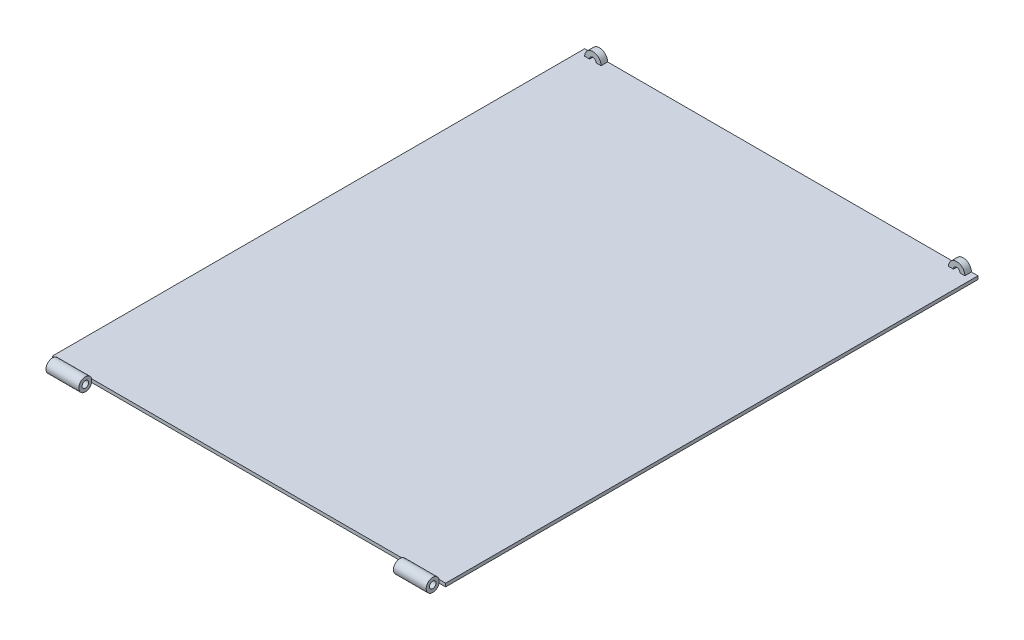
from build123d import *

# Parameters (mm, degrees)
SKETCH1_W                       = 60
SKETCH1_H                       = 82.18
BOSS_EXTRUDE1_DEPTH             = 0.5
BOSS_EXTRUDE2_REACH             = 32
SKETCH3_R                       = 1
SKETCH3_R_2                     = 0.5
BOSS_EXTRUDE2_DIRECTION_2_REACH = 32
SKETCH4_R                       = 0.5
CUT_EXTRUDE1_DEPTH              = 61
SKETCH5_W                       = 48
SKETCH5_H                       = 1.968245837
SKETCH5_W_2                     = 1
CUT_EXTRUDE2_DEPTH              = 1.75
CUT_EXTRUDE2_DEPTH_BACK         = 2.25
BOSS_EXTRUDE3_DEPTH             = 1


with BuildPart() as part:
    # Sketch1 → Boss-Extrude1 (new body)
    with BuildSketch(Plane(origin=(0, 0, 0), x_dir=(1, 0, 0), z_dir=(0, 1, 0))):
        Rectangle(SKETCH1_W, SKETCH1_H)
    extrude(amount=BOSS_EXTRUDE1_DEPTH)

    # Boss-Extrude2: up to this face of the body (flat: up to its plane)
    boss_extrude2_end = Plane(part.part.faces().sort_by_distance((30, 0.25, 0))[0])
    # Sketch3 → Boss-Extrude2 (add, up to the picked face)
    with BuildSketch(Plane(origin=(0, 0, 0), x_dir=(0, 0, -1), z_dir=(1, 0, 0)), mode=Mode.PRIVATE) as boss_extrude2_sk1:
        with Locations((-41.09, 0.25)):
            Circle(SKETCH3_R)
        with Locations((-41.09, 0.25)):
            Circle(SKETCH3_R_2, mode=Mode.SUBTRACT)
    boss_extrude2_tool1 = split(extrude(boss_extrude2_sk1.sketch, amount=BOSS_EXTRUDE2_REACH, mode=Mode.PRIVATE), bisect_by=boss_extrude2_end, keep=Keep.BOTH, mode=Mode.PRIVATE)
    add(boss_extrude2_tool1.solids().sort_by_distance((0, 0.25, 42.061716))[0])

    # Boss-Extrude2 direction 2: up to this face of the body (flat: up to its plane)
    boss_extrude2_direction_2_end = Plane(part.part.faces().sort_by_distance((-30, 0.25, 0))[0])
    # Sketch3 → Boss-Extrude2 direction 2 (add, up to the picked face)
    with BuildSketch(Plane(origin=(0, 0, 0), x_dir=(0, 0, -1), z_dir=(1, 0, 0)), mode=Mode.PRIVATE) as boss_extrude2_direction_2_sk1:
        with Locations((-41.09, 0.25)):
            Circle(SKETCH3_R)
        with Locations((-41.09, 0.25)):
            Circle(SKETCH3_R_2, mode=Mode.SUBTRACT)
    boss_extrude2_direction_2_tool1 = split(extrude(boss_extrude2_direction_2_sk1.sketch, amount=-BOSS_EXTRUDE2_DIRECTION_2_REACH, mode=Mode.PRIVATE), bisect_by=boss_extrude2_direction_2_end, keep=Keep.BOTH, mode=Mode.PRIVATE)
    add(boss_extrude2_direction_2_tool1.solids().sort_by_distance((0, 0.25, 42.061716))[0])

    # Sketch4 → Cut-Extrude1 (cut, through all)
    with BuildSketch(Plane.ZY.offset(30)):
        with Locations((41.09, 0.25)):
            Circle(SKETCH4_R)
    extrude(amount=-CUT_EXTRUDE1_DEPTH, mode=Mode.SUBTRACT)

    # Sketch5 → Cut-Extrude2 (cut, two sides)
    with BuildSketch(Plane(origin=(0, 0.5, 0), x_dir=(1, 0, 0), z_dir=(0, 1, 0))) as cut_extrude2_sk:
        with Locations((0, -41.105877082)):
            Rectangle(SKETCH5_W, SKETCH5_H)
        with Locations((-29.5, -41.105877082)):
            Rectangle(SKETCH5_W_2, SKETCH5_H)
        with Locations((29.5, -41.105877082)):
            Rectangle(SKETCH5_W_2, SKETCH5_H)
    extrude(amount=CUT_EXTRUDE2_DEPTH, mode=Mode.SUBTRACT)
    extrude(cut_extrude2_sk.sketch, amount=-CUT_EXTRUDE2_DEPTH_BACK, mode=Mode.SUBTRACT)

    # Sketch7 → Boss-Extrude3 (add)
    with BuildSketch(Plane(origin=(0, 0, -41.09), x_dir=(-1, 0, 0), z_dir=(0, 0, -1))):
        with BuildLine():
            Line((-29, 0.5), (-28.25, 0.5))
            ThreePointArc((-28.25, 0.5), (-27.75, 1), (-27.25, 0.5))
            Line((-27.25, 0.5), (-26.5, 0.5))
            ThreePointArc((-26.5, 0.5), (-27.75, 1.75), (-29, 0.5))
        make_face()
    boss_extrude3 = extrude(amount=-BOSS_EXTRUDE3_DEPTH)

    # Mirror1: Boss-Extrude3 across plane
    add(boss_extrude3.mirror(Plane(origin=(0, 0, 0), x_dir=(0, 0, 1), z_dir=(1, 0, 0))))


solid = part.part
